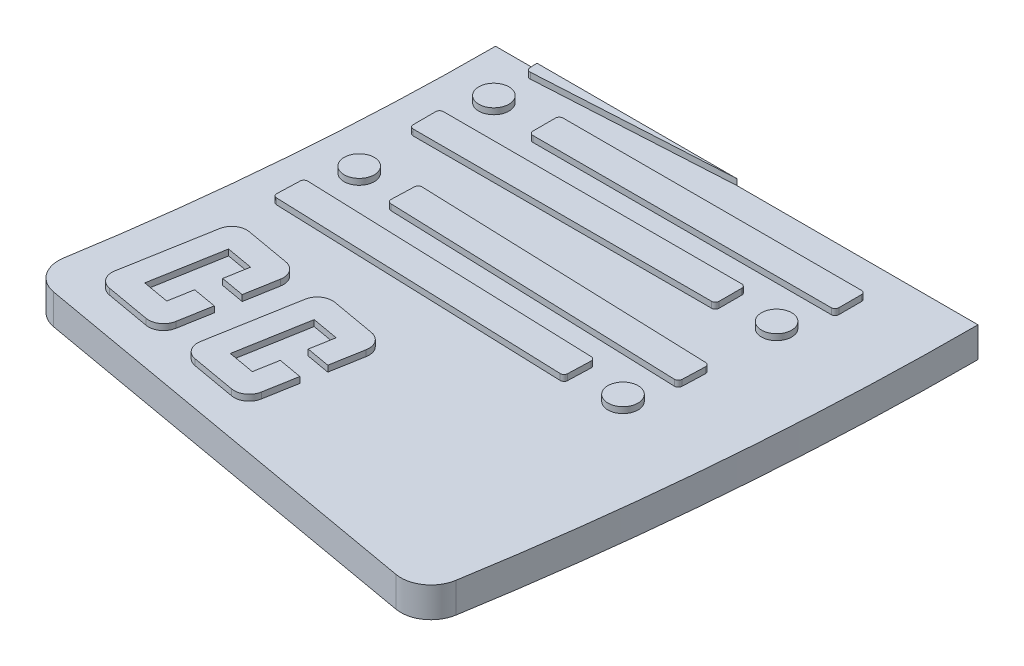
from build123d import *

# Parameters (mm, degrees)
BOSS_EXTRUDE1_DEPTH = 12.7
FILLET1_R           = 12.7
BOSS_EXTRUDE2_DEPTH = 2.54
FILLET2_R           = 6.35
SKETCH3_R           = 6.35
SKETCH3_W           = 128.842678874
SKETCH3_H           = 12.7
BOSS_EXTRUDE3_DEPTH = 2.54
FILLET3_R           = 1.5875


with BuildPart() as part:
    # Sketch1 → Boss-Extrude1 (new body)
    with BuildSketch(Plane(origin=(0, 0, 0), x_dir=(1, 0, 0), z_dir=(0, 1, 0))):
        with BuildLine():
            Line((-101.6, 0), (101.6, 0))
            ThreePointArc((101.6, 0), (96.863119244, -108.334556213), (82.688632431, -215.842221209))
            Line((82.688632431, -215.842221209), (-117.415334702, -180.506087613))
            ThreePointArc((-117.415334702, -180.506087613), (-105.561392761, -90.598803078), (-101.6, 0))
        make_face()
    extrude(amount=BOSS_EXTRUDE1_DEPTH)

    # Fillet1
    fillet1_edges = [part.edges().sort_by_distance(p)[0] for p in [
        (82.688632431, 6.35, 215.842221209),
        (-117.415334702, 6.35, 180.506087613),
    ]]
    fillet(fillet1_edges, radius=FILLET1_R)

    # Sketch2 → Boss-Extrude2 (add)
    with BuildSketch(Plane(origin=(0, 12.7, 0), x_dir=(1, 0, 0), z_dir=(0, 1, 0))):
        Polygon((-54.61463437, -178.699496428), (-23.348389506, -184.220767302), (-19.814776146, -164.210370589), (-29.819974503, -162.443563909), (-31.586781182, -172.448762265), (-42.842629334, -170.461104751), (-37.542209294, -140.445509681), (-26.286361143, -142.433167195), (-28.053167823, -152.438365552), (-18.047969466, -154.205172232), (-14.514356107, -134.194775519), (-45.780600971, -128.673504644), align=None)
        Polygon((-98.387377181, -170.969717203), (-67.121132316, -176.490988078), (-63.587518956, -156.480591364), (-73.592717313, -154.713784685), (-75.359523993, -164.718983041), (-86.615372144, -162.731325527), (-81.314952105, -132.715730457), (-70.059103953, -134.703387971), (-71.825910633, -144.708586328), (-61.820712277, -146.475393008), (-58.287098917, -126.464996294), (-89.553343782, -120.94372542), align=None)
    extrude(amount=BOSS_EXTRUDE2_DEPTH)

    # Fillet2
    fillet2_edges = [part.edges().sort_by_distance(p)[0] for p in [
        (-67.121132316, 13.97, 176.490988078),
        (-58.287098917, 13.97, 126.464996294),
        (-89.553343782, 13.97, 120.94372542),
        (-98.387377181, 13.97, 170.969717203),
        (-23.348389506, 13.97, 184.220767302),
        (-14.514356107, 13.97, 134.194775519),
        (-45.780600971, 13.97, 128.673504644),
        (-54.61463437, 13.97, 178.699496428),
    ]]
    fillet(fillet2_edges, radius=FILLET2_R)

    # Sketch3 → Boss-Extrude3 (add)
    with BuildSketch(Plane(origin=(0, 12.7, 0), x_dir=(1, 0, 0), z_dir=(0, 1, 0))):
        with Locations((-84.061485004, -74.95573952)):
            Circle(SKETCH3_R)
        with Locations((54.755611036, -102.677273515)):
            Circle(SKETCH3_R)
        with Locations((-81.443399967, -20.868490804)):
            Circle(SKETCH3_R)
        with Locations((60.495827673, -43.728490804)):
            Circle(SKETCH3_R)
        Polygon((-65.244701553, -81.966706683), (61.677933479, -86.398942765), (62.121157087, -73.706679262), (-64.801477945, -69.27444318), align=None)
        Polygon((-91.427031054, -103.926333773), (35.495603978, -108.358569854), (35.938827586, -95.666306351), (-90.983807446, -91.23407027), align=None)
        with Locations((4.18018601, -20.868490804)):
            Rectangle(SKETCH3_W, SKETCH3_H)
        with Locations((-23.37206053, -43.728490804)):
            Rectangle(SKETCH3_W, SKETCH3_H)
        Polygon((-84.153810009, 0), (-83.882599151, -4.769682556), (0, 0), align=None)
    extrude(amount=BOSS_EXTRUDE3_DEPTH)

    # Fillet3
    fillet3_edges = [part.edges().sort_by_distance(p)[0] for p in [
        (-64.801477945, 13.97, 69.27444318),
        (-65.244701553, 13.97, 81.966706683),
        (61.677933479, 13.97, 86.398942765),
        (62.121157087, 13.97, 73.706679262),
        (-83.882599151, 13.97, 4.769682556),
        (-90.983807446, 13.97, 91.23407027),
        (-91.427031054, 13.97, 103.926333773),
        (35.495603978, 13.97, 108.358569854),
        (35.938827586, 13.97, 95.666306351),
        (-60.241153427, 13.97, 14.518490804),
        (-60.241153427, 13.97, 27.218490804),
        (68.601525447, 13.97, 27.218490804),
        (68.601525447, 13.97, 14.518490804),
        (-87.793399967, 13.97, 37.378490804),
        (-87.793399967, 13.97, 50.078490804),
        (41.049278907, 13.97, 50.078490804),
        (41.049278907, 13.97, 37.378490804),
    ]]
    fillet(fillet3_edges, radius=FILLET3_R)


solid = part.part
